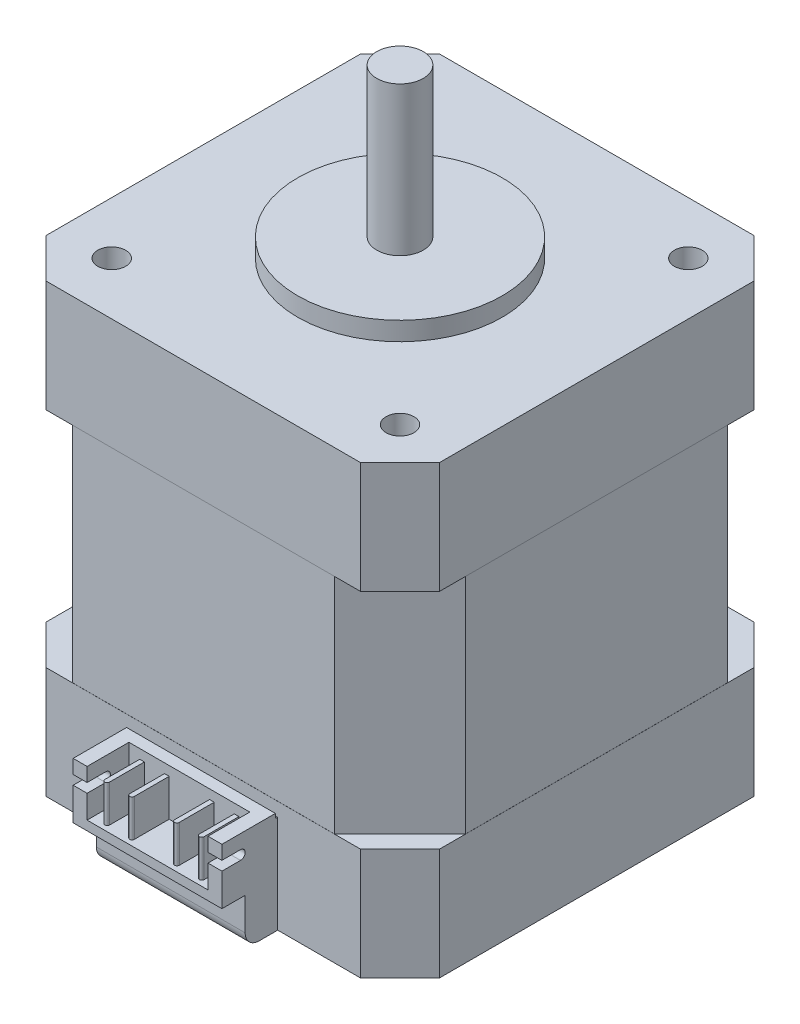
from build123d import *

# Parameters (mm, degrees)
SKETCH1_W               = 42.3
SKETCH1_H               = 42.3
BOSS_EXTRUDE1_DEPTH     = 48
SKETCH2_R               = 11
BOSS_EXTRUDE2_DEPTH     = 2
SKETCH3_R               = 2.5
BOSS_EXTRUDE3_DEPTH     = 16
CUT_EXTRUDE1_DEPTH      = 19
CUT_EXTRUDE1_DEPTH_BACK = 49
SKETCH5_W               = 33.814718626
SKETCH5_H               = 24
CUT_EXTRUDE2_DEPTH      = 0.01
CUT_EXTRUDE3_START      = -12
CUT_EXTRUDE3_DEPTH      = 24
CIRPATTERN1_COUNT       = 4
SKETCH7_R               = 1.5
CUT_EXTRUDE4_DEPTH      = 4.5
SKETCH8_W               = 16
SKETCH8_H               = 11
BOSS_EXTRUDE4_DEPTH     = 6
SKETCH9_W               = 16
SKETCH9_H               = 5
CUT_EXTRUDE5_DEPTH      = 2.5
FILLET1_R               = 1.5
SKETCH10_W              = 13
SKETCH10_H              = 4.5
CUT_EXTRUDE6_DEPTH      = 5
CUT_EXTRUDE7_DEPTH      = 30.15
BOSS_EXTRUDE5_DEPTH     = 4
SKETCH13_W              = 16
SKETCH13_H              = 0.25
CUT_EXTRUDE8_DEPTH      = 0.5
FILLET2_R               = 0.125


with BuildPart() as part:
    # Sketch1 → Boss-Extrude1 (new body)
    with BuildSketch(Plane(origin=(0, 0, 0), x_dir=(1, 0, 0), z_dir=(0, 1, 0))):
        Rectangle(SKETCH1_W, SKETCH1_H)
    extrude(amount=BOSS_EXTRUDE1_DEPTH)

    # Sketch2 → Boss-Extrude2 (add)
    with BuildSketch(Plane(origin=(0, 48, 0), x_dir=(1, 0, 0), z_dir=(0, 1, 0))):
        Circle(SKETCH2_R)
    extrude(amount=BOSS_EXTRUDE2_DEPTH)

    # Sketch3 → Boss-Extrude3 (add)
    with BuildSketch(Plane(origin=(0, 50, 0), x_dir=(1, 0, 0), z_dir=(0, 1, 0))):
        Circle(SKETCH3_R)
    extrude(amount=BOSS_EXTRUDE3_DEPTH)

    # Sketch4 → Cut-Extrude1 (cut, two sides)
    with BuildSketch(Plane(origin=(0, 48, 0), x_dir=(1, 0, 0), z_dir=(0, 1, 0))) as cut_extrude1_sk:
        Polygon((-21.15, 16.907359313), (-16.907359313, 21.15), (-21.15, 21.15), align=None)
        Polygon((21.15, 21.15), (21.15, 16.907359313), (16.907359313, 21.15), align=None)
        Polygon((21.15, -16.907359313), (16.907359313, -21.15), (21.15, -21.15), align=None)
        Polygon((-21.15, -21.15), (-21.15, -16.907359313), (-16.907359313, -21.15), align=None)
    extrude(amount=CUT_EXTRUDE1_DEPTH, mode=Mode.SUBTRACT)
    extrude(cut_extrude1_sk.sketch, amount=-CUT_EXTRUDE1_DEPTH_BACK, mode=Mode.SUBTRACT)

    # Sketch5 → Cut-Extrude2 (cut)
    with BuildSketch(Plane(origin=(21.15, 0, 0), x_dir=(0, 0, -1), z_dir=(1, 0, 0))):
        with Locations((0, 24)):
            Rectangle(SKETCH5_W, SKETCH5_H)
    cut_extrude2 = extrude(amount=-CUT_EXTRUDE2_DEPTH, mode=Mode.SUBTRACT)

    # Sketch6 → Cut-Extrude3 (cut)
    with BuildSketch(Plane(origin=(0, 48, 0), x_dir=(1, 0, 0), z_dir=(0, 1, 0)).offset(CUT_EXTRUDE3_START)):
        Polygon((21.15, 14.078932188), (14.078932188, 21.15), (21.15, 21.15), align=None)
    cut_extrude3 = extrude(amount=-CUT_EXTRUDE3_DEPTH, mode=Mode.SUBTRACT)

    # CirPattern1: Cut-Extrude2, Cut-Extrude3 ×4 about axis
    cirpattern1_axis = Axis((0, 0, 0), (0, 1, 0))
    for i in range(1, CIRPATTERN1_COUNT):
        add(cut_extrude2.rotate(cirpattern1_axis, i * 360 / CIRPATTERN1_COUNT), mode=Mode.SUBTRACT)
        add(cut_extrude3.rotate(cirpattern1_axis, i * 360 / CIRPATTERN1_COUNT), mode=Mode.SUBTRACT)

    # Sketch7 → Cut-Extrude4 (cut)
    with BuildSketch(Plane(origin=(0, 48, 0), x_dir=(1, 0, 0), z_dir=(0, 1, 0))):
        with Locations((15.5, 15.5)):
            Circle(SKETCH7_R)
        with Locations((15.5, -15.5)):
            Circle(SKETCH7_R)
        with Locations((-15.5, -15.5)):
            Circle(SKETCH7_R)
        with Locations((-15.5, 15.5)):
            Circle(SKETCH7_R)
    extrude(amount=-CUT_EXTRUDE4_DEPTH, mode=Mode.SUBTRACT)

    # Sketch8 → Boss-Extrude4 (add)
    with BuildSketch(Plane.XY.offset(21.15)):
        with Locations((0, 5.5)):
            Rectangle(SKETCH8_W, SKETCH8_H)
    extrude(amount=BOSS_EXTRUDE4_DEPTH)

    # Sketch9 → Cut-Extrude5 (cut)
    with BuildSketch(Plane.XY.offset(27.15)):
        with Locations((0, 2.5)):
            Rectangle(SKETCH9_W, SKETCH9_H)
    extrude(amount=-CUT_EXTRUDE5_DEPTH, mode=Mode.SUBTRACT)

    # Fillet1
    fillet1_edges = [part.edges().sort_by_distance(p)[0] for p in [
        (0, 0, 24.65),
    ]]
    fillet(fillet1_edges, radius=FILLET1_R)

    # Sketch10 → Cut-Extrude6 (cut)
    with BuildSketch(Plane(origin=(0, 11, 0), x_dir=(1, 0, 0), z_dir=(0, 1, 0))):
        with Locations((0, -24.9)):
            Rectangle(SKETCH10_W, SKETCH10_H)
    extrude(amount=-CUT_EXTRUDE6_DEPTH, mode=Mode.SUBTRACT)

    # Sketch11 → Cut-Extrude7 (cut, through all)
    with BuildSketch(Plane(origin=(8, 0, 0), x_dir=(0, 0, -1), z_dir=(1, 0, 0))):
        with BuildLine():
            Line((-27.15, 9.5), (-25.15, 9.5))
            ThreePointArc((-25.15, 9.5), (-24.65, 9), (-25.15, 8.5))
            Line((-25.15, 8.5), (-27.15, 8.5))
            Line((-27.15, 8.5), (-27.15, 9.5))
        make_face()
    extrude(amount=-CUT_EXTRUDE7_DEPTH, mode=Mode.SUBTRACT)

    # Sketch12 → Boss-Extrude5 (add)
    with BuildSketch(Plane(origin=(0, 6, 0), x_dir=(1, 0, 0), z_dir=(0, 1, 0))):
        with BuildLine():
            Line((-2.667, -22.65), (-2.167, -22.65))
            Line((-2.167, -22.65), (-2.167, -26.4))
            ThreePointArc((-2.167, -26.4), (-2.417, -26.65), (-2.667, -26.4))
            Line((-2.667, -26.4), (-2.667, -22.65))
        make_face()
        with BuildLine():
            Line((5.334, -22.65), (5.334, -26.4))
            ThreePointArc((5.334, -26.4), (5.084, -26.65), (4.834, -26.4))
            Line((4.834, -26.4), (4.834, -22.65))
            Line((4.834, -22.65), (5.334, -22.65))
        make_face()
        with BuildLine():
            Line((-4.834, -22.65), (-5.334, -22.65))
            Line((-5.334, -22.65), (-5.334, -26.4))
            ThreePointArc((-5.334, -26.4), (-5.084, -26.65), (-4.834, -26.4))
            Line((-4.834, -26.4), (-4.834, -22.65))
        make_face()
        with BuildLine():
            Line((2.167, -22.65), (2.167, -26.4))
            ThreePointArc((2.167, -26.4), (2.417, -26.65), (2.667, -26.4))
            Line((2.667, -26.4), (2.667, -22.65))
            Line((2.667, -22.65), (2.167, -22.65))
        make_face()
    extrude(amount=BOSS_EXTRUDE5_DEPTH)

    # Sketch13 → Cut-Extrude8 (cut)
    with BuildSketch(Plane(origin=(0, 11, 0), x_dir=(1, 0, 0), z_dir=(0, 1, 0))):
        with Locations((0, -21.275)):
            Rectangle(SKETCH13_W, SKETCH13_H)
    extrude(amount=-CUT_EXTRUDE8_DEPTH, mode=Mode.SUBTRACT)

    # Fillet2
    fillet2_edges = [part.edges().sort_by_distance(p)[0] for p in [
        (0, 10.5, 21.4),
    ]]
    fillet(fillet2_edges, radius=FILLET2_R)


solid = part.part
